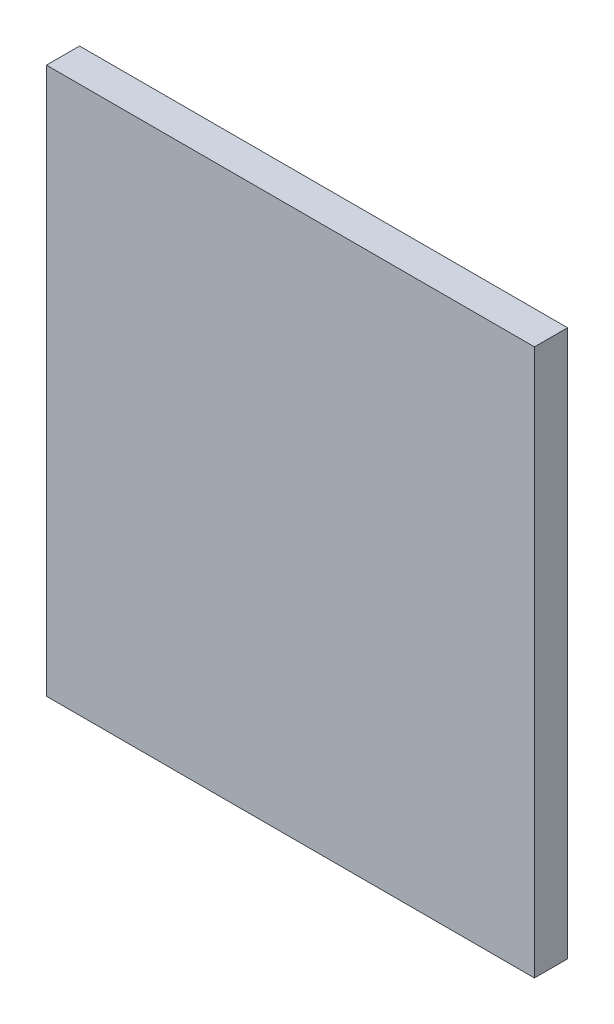
from build123d import *

# Parameters (mm, degrees)
SKETCH1_W           = 29.48
SKETCH1_H           = 33.02
BOSS_EXTRUDE1_DEPTH = 2


with BuildPart() as part:
    # Sketch1 → Boss-Extrude1 (new body)
    with BuildSketch(Plane.XY):
        with Locations((16.095470738, -3.780916031)):
            Rectangle(SKETCH1_W, SKETCH1_H)
    extrude(amount=BOSS_EXTRUDE1_DEPTH)


solid = part.part
